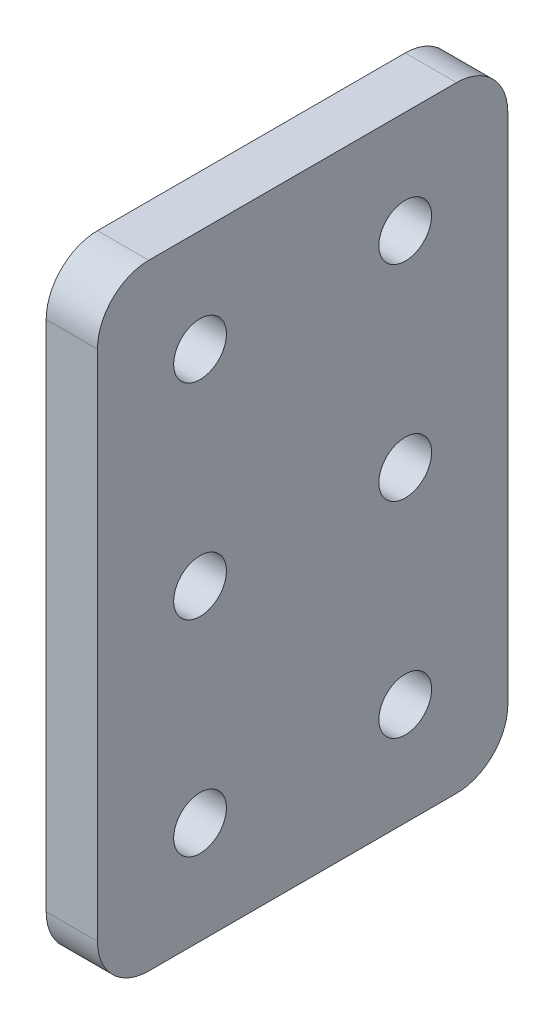
from build123d import *

# Parameters (mm, degrees)
SKETCH1_W      = 50.8
SKETCH1_H      = 76.2
SKETCH1_R      = 3.2639
EXTRUDE1_DEPTH = 6.35
FILLET1_R      = 6.35


with BuildPart() as part:
    # Sketch1 → Extrude1 (new body)
    with BuildSketch(Plane(origin=(0, 0, 0), x_dir=(0, 0, -1), z_dir=(1, 0, 0))):
        with Locations((25.4, 38.1)):
            Rectangle(SKETCH1_W, SKETCH1_H)
        with Locations((12.7, 63.5)):
            Circle(SKETCH1_R, mode=Mode.SUBTRACT)
        with Locations((38.1, 63.5)):
            Circle(SKETCH1_R, mode=Mode.SUBTRACT)
        with Locations((12.7, 38.1)):
            Circle(SKETCH1_R, mode=Mode.SUBTRACT)
        with Locations((38.1, 38.1)):
            Circle(SKETCH1_R, mode=Mode.SUBTRACT)
        with Locations((12.7, 12.7)):
            Circle(SKETCH1_R, mode=Mode.SUBTRACT)
        with Locations((38.1, 12.7)):
            Circle(SKETCH1_R, mode=Mode.SUBTRACT)
    extrude(amount=EXTRUDE1_DEPTH)

    # Fillet1
    fillet1_edges = [part.edges().sort_by_distance(p)[0] for p in [
        (3.175, 76.2, 0),
        (3.175, 76.2, -50.8),
        (3.175, 0, -50.8),
        (3.175, 0, 0),
    ]]
    fillet(fillet1_edges, radius=FILLET1_R)


solid = part.part
